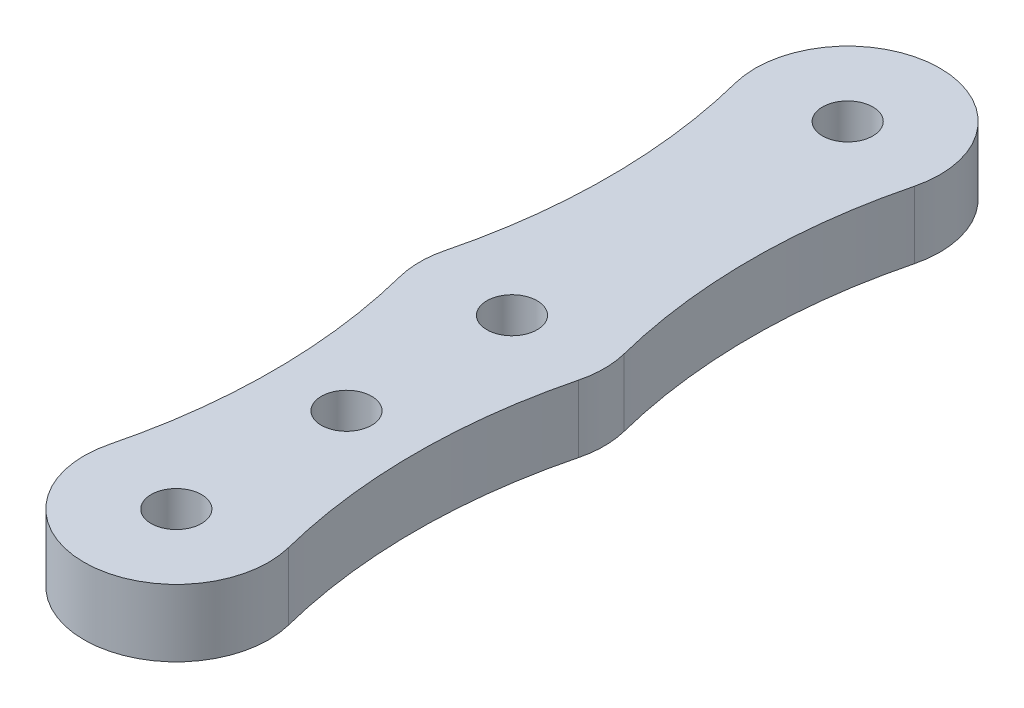
from build123d import *

# Parameters (mm, degrees)
SKETCH1_R           = 1.5
BOSS_EXTRUDE1_DEPTH = 4


with BuildPart() as part:
    # Sketch1 → Boss-Extrude1 (new body)
    with BuildSketch(Plane(origin=(0, 0, 0), x_dir=(1, 0, 0), z_dir=(0, 1, 0))):
        with BuildLine():
            ThreePointArc((-5.330769231, 1.353846154), (0, -5.5), (5.330769231, 1.353846154))
            ThreePointArc((5.330769231, 1.353846154), (4.25, 10), (5.330769231, 18.646153846))
            ThreePointArc((5.330769231, 18.646153846), (5.5, 20), (5.330769231, 21.353846154))
            ThreePointArc((5.330769231, 21.353846154), (4.25, 30), (5.330769231, 38.646153846))
            ThreePointArc((5.330769231, 38.646153846), (0, 45.5), (-5.330769231, 38.646153846))
            ThreePointArc((-5.330769231, 38.646153846), (-4.25, 30), (-5.330769231, 21.353846154))
            ThreePointArc((-5.330769231, 21.353846154), (-5.5, 20), (-5.330769231, 18.646153846))
            ThreePointArc((-5.330769231, 18.646153846), (-4.25, 10), (-5.330769231, 1.353846154))
        make_face()
        Circle(SKETCH1_R, mode=Mode.SUBTRACT)
        with Locations((0, 40)):
            Circle(SKETCH1_R, mode=Mode.SUBTRACT)
        with Locations((0, 10.14)):
            Circle(SKETCH1_R, mode=Mode.SUBTRACT)
        with Locations((0, 20)):
            Circle(SKETCH1_R, mode=Mode.SUBTRACT)
    extrude(amount=BOSS_EXTRUDE1_DEPTH)


solid = part.part
